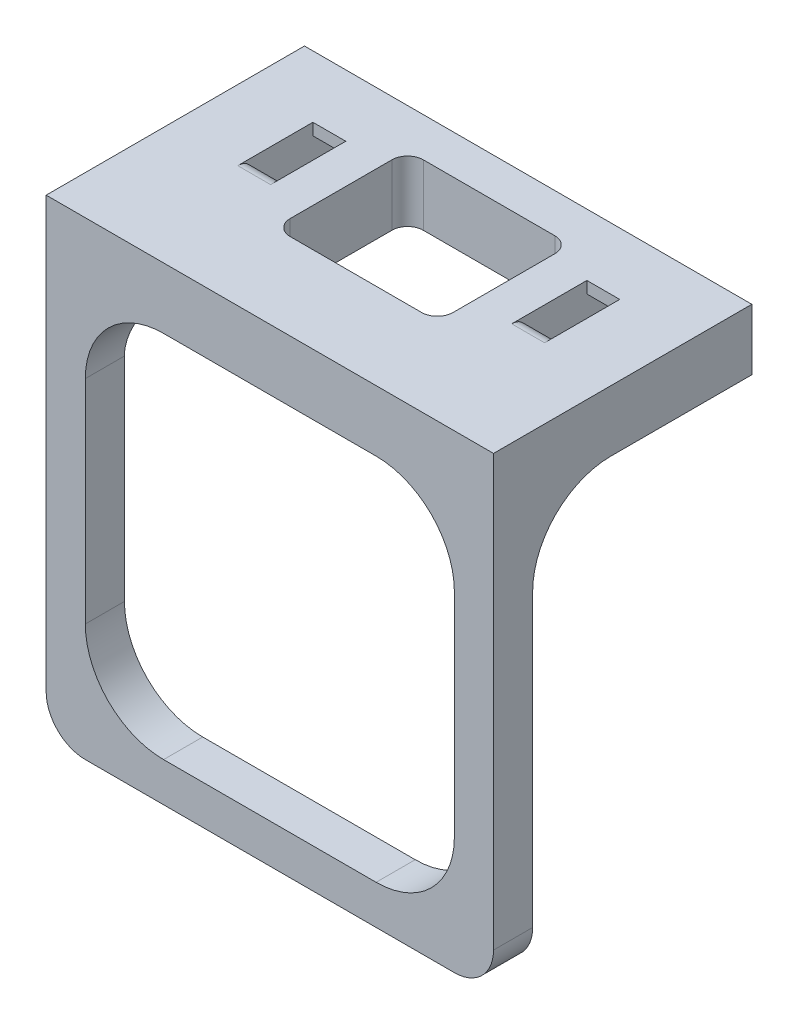
from build123d import *

# Parameters (mm, degrees)
SKETCH1_W               = 57.15
SKETCH1_H               = 33
BOSS_EXTRUDE1_DEPTH     = 10
SKETCH2_W               = 4.2
SKETCH2_H               = 11
CUT_EXTRUDE1_DEPTH      = 5.8
BOSS_EXTRUDE2_START     = -43.975
BOSS_EXTRUDE2_DEPTH     = 55.8
SKETCH4_W               = 33
SKETCH4_H               = 2.2
CUT_EXTRUDE2_DEPTH      = 1
CUT_EXTRUDE2_DEPTH_BACK = 58.15
FILLET1_R               = 2
SKETCH7_W               = 20.8
SKETCH7_H               = 17
CUT_EXTRUDE4_DEPTH      = 16
FILLET2_R               = 2
BOSS_EXTRUDE4_START     = -7.8
SKETCH5_W               = 57.15
SKETCH5_H               = 5
BOSS_EXTRUDE4_DEPTH     = 52.15
SKETCH8_W               = 47.15
SKETCH8_H               = 47.15
CUT_EXTRUDE5_DEPTH      = 52.15
FILLET3_R               = 10
FILLET4_R               = 5


with BuildPart() as part:
    # Sketch1 → Boss-Extrude1 (new body)
    with BuildSketch(Plane(origin=(0, 0, 0), x_dir=(1, 0, 0), z_dir=(0, 1, 0))):
        with Locations((28.575, 16.5)):
            Rectangle(SKETCH1_W, SKETCH1_H)
    extrude(amount=BOSS_EXTRUDE1_DEPTH)

    # Sketch2 → Cut-Extrude1 (cut)
    with BuildSketch(Plane(origin=(0, 10, 0), x_dir=(1, 0, 0), z_dir=(0, 1, 0))):
        with Locations((11.075, 23)):
            Rectangle(SKETCH2_W, SKETCH2_H)
        with Locations((46.075, 23)):
            Rectangle(SKETCH2_W, SKETCH2_H)
    extrude(amount=-CUT_EXTRUDE1_DEPTH, mode=Mode.SUBTRACT)

    # Sketch3 → Boss-Extrude2 (add)
    with BuildSketch(Plane.ZY.offset(-13.175).offset(BOSS_EXTRUDE2_START)):
        Polygon((-28.5, 5.85), (-25.1, 8.5), (-25.1, 10), (-28.5, 10), align=None)
    extrude(amount=BOSS_EXTRUDE2_DEPTH)

    # Sketch4 → Cut-Extrude2 (cut, two sides)
    with BuildSketch(Plane(origin=(57.15, 0, 0), x_dir=(0, 0, -1), z_dir=(1, 0, 0))) as cut_extrude2_sk:
        with Locations((16.5, 1.1)):
            Rectangle(SKETCH4_W, SKETCH4_H)
    extrude(amount=CUT_EXTRUDE2_DEPTH, mode=Mode.SUBTRACT)
    extrude(cut_extrude2_sk.sketch, amount=-CUT_EXTRUDE2_DEPTH_BACK, mode=Mode.SUBTRACT)

    # Fillet1
    fillet1_edges = [part.edges().sort_by_distance(p)[0] for p in [
        (11.075, 10, -17.5),
        (46.075, 10, -17.5),
    ]]
    fillet(fillet1_edges, radius=FILLET1_R)

    # Sketch7 → Cut-Extrude4 (cut)
    with BuildSketch(Plane(origin=(0, 10, 0), x_dir=(1, 0, 0), z_dir=(0, 1, 0))):
        with Locations((28.575, 19.5)):
            Rectangle(SKETCH7_W, SKETCH7_H)
    extrude(amount=-CUT_EXTRUDE4_DEPTH, mode=Mode.SUBTRACT)

    # Fillet2
    fillet2_edges = [part.edges().sort_by_distance(p)[0] for p in [
        (18.175, 6.1, -11),
        (18.175, 6.1, -28),
        (38.975, 6.1, -28),
        (38.975, 6.1, -11),
    ]]
    fillet(fillet2_edges, radius=FILLET2_R)

    # Sketch5 → Boss-Extrude4 (add)
    with BuildSketch(Plane(origin=(0, 10, 0), x_dir=(1, 0, 0), z_dir=(0, 1, 0)).offset(BOSS_EXTRUDE4_START)):
        with Locations((28.575, 2.5)):
            Rectangle(SKETCH5_W, SKETCH5_H)
    extrude(amount=-BOSS_EXTRUDE4_DEPTH)

    # Sketch8 → Cut-Extrude5 (cut)
    with BuildSketch(Plane(origin=(0, 0, -5), x_dir=(-1, 0, 0), z_dir=(0, 0, -1))):
        with Locations((-28.575, -21.375)):
            Rectangle(SKETCH8_W, SKETCH8_H)
    extrude(amount=-CUT_EXTRUDE5_DEPTH, mode=Mode.SUBTRACT)

    # Fillet3
    fillet3_edges = [part.edges().sort_by_distance(p)[0] for p in [
        (54.65, 2.2, -5),
        (2.5, 2.2, -5),
        (52.15, -44.95, -2.5),
        (52.15, 2.2, -2.5),
        (5, 2.2, -2.5),
        (5, -44.95, -2.5),
    ]]
    fillet(fillet3_edges, radius=FILLET3_R)

    # Fillet4
    fillet4_edges = [part.edges().sort_by_distance(p)[0] for p in [
        (57.15, -49.95, -2.5),
        (0, -49.95, -2.5),
    ]]
    fillet(fillet4_edges, radius=FILLET4_R)


solid = part.part
